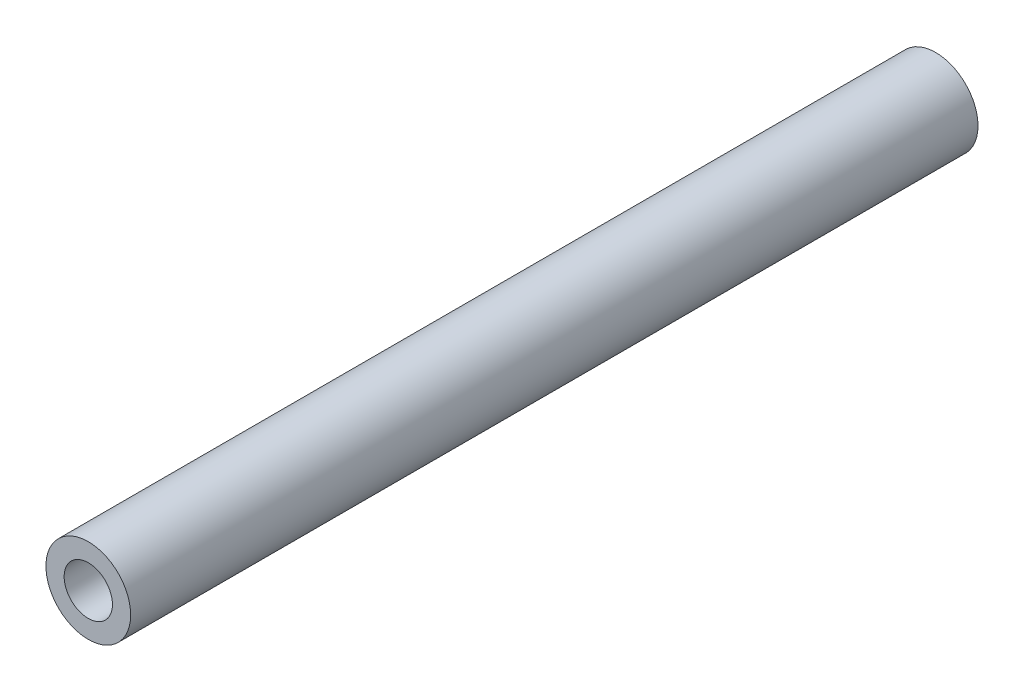
from build123d import *

# Parameters (mm, degrees)
ESBO_O1_R                = 5
ESBO_O1_R_2              = 2.85
RESSALTO_EXTRUS_O1_DEPTH = 100


with BuildPart() as part:
    # Esboço1 → Ressalto-extrusão1 (new body)
    with BuildSketch(Plane.XY):
        Circle(ESBO_O1_R)
        Circle(ESBO_O1_R_2, mode=Mode.SUBTRACT)
    extrude(amount=RESSALTO_EXTRUS_O1_DEPTH)


solid = part.part
